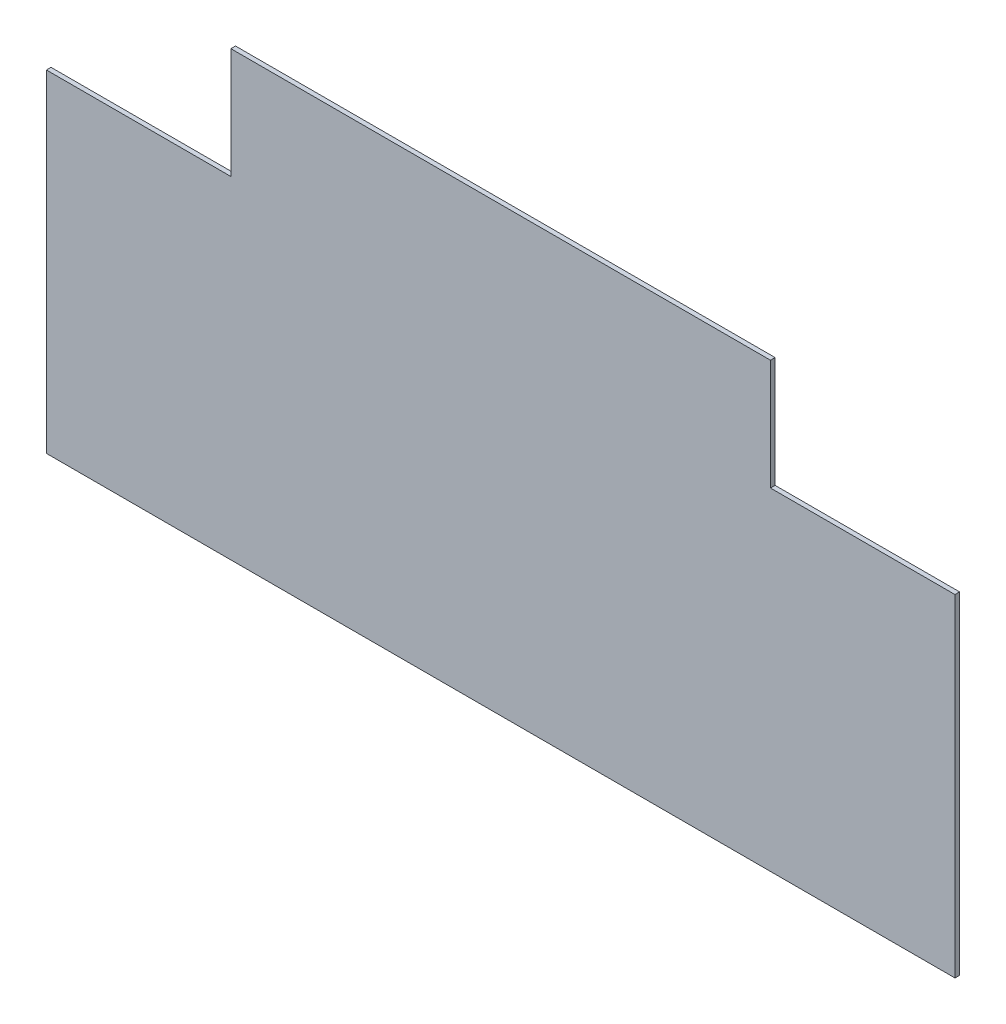
from build123d import *

# Parameters (mm, degrees)
BOSS_EXTRUDE1_DEPTH = 3.175


with BuildPart() as part:
    # Sketch1 → Boss-Extrude1 (new body)
    with BuildSketch(Plane.XY):
        Polygon((498.475, 228.6), (625.475, 228.6), (625.475, 0), (0, 0), (0, 228.6), (127, 228.6), (127, 304.8), (498.475, 304.8), align=None)
    extrude(amount=BOSS_EXTRUDE1_DEPTH)


solid = part.part
